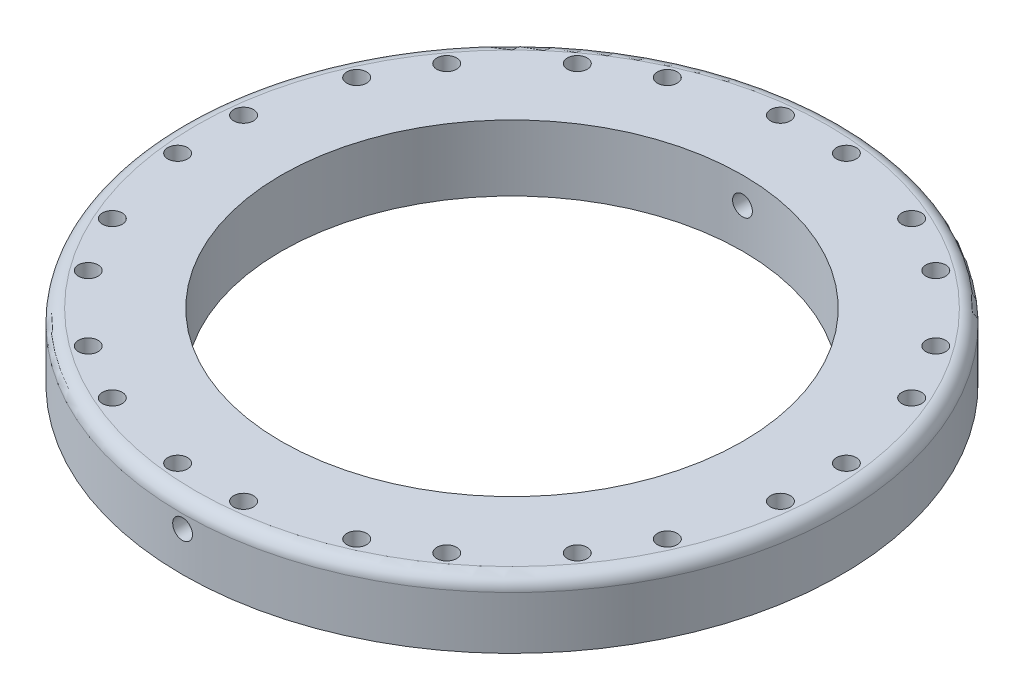
from build123d import *

# Parameters (mm, degrees)
SKICA1_R                      = 250
P_IDAT_VYSUNUT_M1_DEPTH       = 50
SKICA2_R                      = 175
ODEBRAT_VYSUNUT_M1_DEPTH      = 60
ZAOBLIT1_R                    = 10
SKICA4_R                      = 7.5
ODEBRAT_VYSUNUT_M2_DEPTH      = 51
SKICA6_R                      = 7.5
ODEBRAT_VYSUNUT_M3_DEPTH      = 251
ODEBRAT_VYSUNUT_M3_DEPTH_BACK = 251


with BuildPart() as part:
    # Skica1 → Přidat vysunutím1 (new body)
    with BuildSketch(Plane(origin=(0, 0, 0), x_dir=(1, 0, 0), z_dir=(0, 1, 0))):
        with Locations(Location((0, 0, 0), (0, 0, 270))):  # turned: the seam where the file's is
            Circle(SKICA1_R)
    extrude(amount=-P_IDAT_VYSUNUT_M1_DEPTH)

    # Skica2 → Odebrat vysunutím1 (cut)
    with BuildSketch(Plane(origin=(0, 0, 0), x_dir=(1, 0, 0), z_dir=(0, 1, 0))):
        with Locations(Location((0, 0, 0), (0, 0, 270))):  # turned: the seam where the file's is
            Circle(SKICA2_R)
    extrude(amount=-ODEBRAT_VYSUNUT_M1_DEPTH, mode=Mode.SUBTRACT)

    # Zaoblit1
    zaoblit1_edges = [part.edges().sort_by_distance(p)[0] for p in [
        (0, 0, -250),
    ]]
    fillet(zaoblit1_edges, radius=ZAOBLIT1_R)

    # Skica4 → Odebrat vysunutím2 (cut, through all)
    with BuildSketch(Plane(origin=(0, 0, 0), x_dir=(1, 0, 0), z_dir=(0, 1, 0))):
        with Locations(Location((-25, -228.637267303, 0), (0, 0, 270))):  # turned: the seam where the file's is
            Circle(SKICA4_R)
        with Locations(Location((25, -228.637267303, 0), (0, 0, 90))):  # turned: the seam where the file's is
            Circle(SKICA4_R)
        with Locations(Location((-135.969268746, -185.505681737, 0), (0, 0, 270))):  # turned: the seam where the file's is
            Circle(SKICA4_R)
        with Locations(Location((-92.667998557, -210.505681737, 0), (0, 0, 90))):  # turned: the seam where the file's is
            Circle(SKICA4_R)
        with Locations(Location((-210.505681737, -92.667998557, 0), (0, 0, 270))):  # turned: the seam where the file's is
            Circle(SKICA4_R)
        with Locations(Location((-185.505681737, -135.969268746, 0), (0, 0, 90))):  # turned: the seam where the file's is
            Circle(SKICA4_R)
        with Locations(Location((-228.637267303, 25, 0), (0, 0, 270))):  # turned: the seam where the file's is
            Circle(SKICA4_R)
        with Locations(Location((-228.637267303, -25, 0), (0, 0, 90))):  # turned: the seam where the file's is
            Circle(SKICA4_R)
        with Locations(Location((-185.505681737, 135.969268746, 0), (0, 0, 270))):  # turned: the seam where the file's is
            Circle(SKICA4_R)
        with Locations(Location((-210.505681737, 92.667998557, 0), (0, 0, 90))):  # turned: the seam where the file's is
            Circle(SKICA4_R)
        with Locations(Location((-92.667998557, 210.505681737, 0), (0, 0, 270))):  # turned: the seam where the file's is
            Circle(SKICA4_R)
        with Locations(Location((-135.969268746, 185.505681737, 0), (0, 0, 90))):  # turned: the seam where the file's is
            Circle(SKICA4_R)
        with Locations(Location((25, 228.637267303, 0), (0, 0, 270))):  # turned: the seam where the file's is
            Circle(SKICA4_R)
        with Locations(Location((-25, 228.637267303, 0), (0, 0, 90))):  # turned: the seam where the file's is
            Circle(SKICA4_R)
        with Locations(Location((135.969268746, 185.505681737, 0), (0, 0, 270))):  # turned: the seam where the file's is
            Circle(SKICA4_R)
        with Locations(Location((92.667998557, 210.505681737, 0), (0, 0, 90))):  # turned: the seam where the file's is
            Circle(SKICA4_R)
        with Locations(Location((210.505681737, 92.667998557, 0), (0, 0, 270))):  # turned: the seam where the file's is
            Circle(SKICA4_R)
        with Locations(Location((185.505681737, 135.969268746, 0), (0, 0, 90))):  # turned: the seam where the file's is
            Circle(SKICA4_R)
        with Locations(Location((228.637267303, -25, 0), (0, 0, 270))):  # turned: the seam where the file's is
            Circle(SKICA4_R)
        with Locations(Location((228.637267303, 25, 0), (0, 0, 90))):  # turned: the seam where the file's is
            Circle(SKICA4_R)
        with Locations(Location((185.505681737, -135.969268746, 0), (0, 0, 270))):  # turned: the seam where the file's is
            Circle(SKICA4_R)
        with Locations(Location((210.505681737, -92.667998557, 0), (0, 0, 90))):  # turned: the seam where the file's is
            Circle(SKICA4_R)
        with Locations(Location((92.667998557, -210.505681737, 0), (0, 0, 270))):  # turned: the seam where the file's is
            Circle(SKICA4_R)
        with Locations(Location((135.969268746, -185.505681737, 0), (0, 0, 90))):  # turned: the seam where the file's is
            Circle(SKICA4_R)
    extrude(amount=-ODEBRAT_VYSUNUT_M2_DEPTH, mode=Mode.SUBTRACT)

    # Skica6 → Odebrat vysunutím3 (cut, two sides)
    with BuildSketch(Plane.XY) as odebrat_vysunut_m3_sk:
        with Locations((0, -20)):
            Circle(SKICA6_R)
    extrude(amount=ODEBRAT_VYSUNUT_M3_DEPTH, mode=Mode.SUBTRACT)
    extrude(odebrat_vysunut_m3_sk.sketch, amount=-ODEBRAT_VYSUNUT_M3_DEPTH_BACK, mode=Mode.SUBTRACT)


solid = part.part
